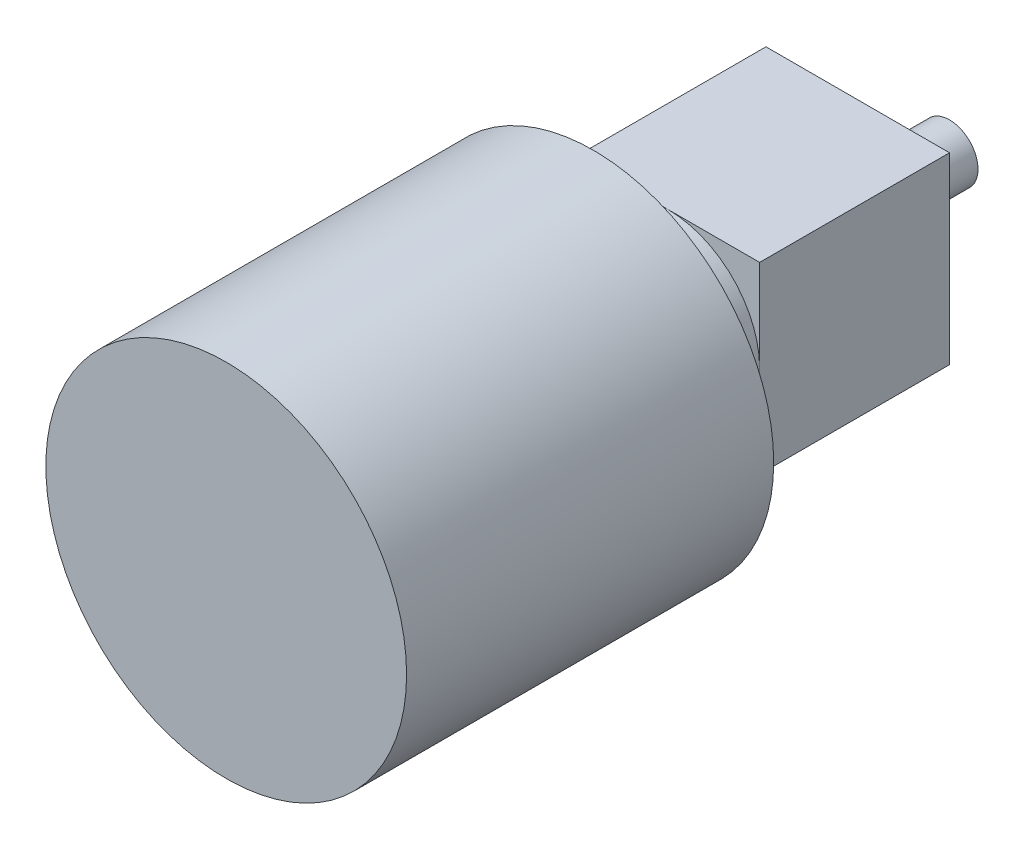
from build123d import *

# Parameters (mm, degrees)
SKETCH1_W           = 29
SKETCH1_H           = 30
BOSS_EXTRUDE1_DEPTH = 29
SKETCH2_R           = 14.5
BOSS_EXTRUDE2_DEPTH = 11.78
SKETCH3_R           = 1.2
CUT_EXTRUDE1_DEPTH  = 2.5
SKETCH4_R           = 4.5
BOSS_EXTRUDE3_DEPTH = 6
SKETCH5_R           = 28.5
BOSS_EXTRUDE4_DEPTH = 58


with BuildPart() as part:
    # Sketch1 → Boss-Extrude1 (new body)
    with BuildSketch(Plane(origin=(0, 0, 0), x_dir=(1, 0, 0), z_dir=(0, 1, 0))):
        Rectangle(SKETCH1_W, SKETCH1_H)
    extrude(amount=BOSS_EXTRUDE1_DEPTH)

    # Sketch2 → Boss-Extrude2 (add)
    with BuildSketch(Plane.XY.offset(15)):
        with Locations((0, 14.5)):
            Circle(SKETCH2_R)
    extrude(amount=BOSS_EXTRUDE2_DEPTH)

    # Sketch3 → Cut-Extrude1 (cut)
    with BuildSketch(Plane.XZ):
        with Locations((-10, 12)):
            Circle(SKETCH3_R)
        with Locations((10, 12)):
            Circle(SKETCH3_R)
        with Locations((0, -11.5)):
            Circle(SKETCH3_R)
    extrude(amount=-CUT_EXTRUDE1_DEPTH, mode=Mode.SUBTRACT)

    # Sketch4 → Boss-Extrude3 (add)
    with BuildSketch(Plane(origin=(0, 0, -15), x_dir=(-1, 0, 0), z_dir=(0, 0, -1))):
        with Locations((-8.5, 23)):
            Circle(SKETCH4_R)
    extrude(amount=BOSS_EXTRUDE3_DEPTH)

    # Sketch5 → Boss-Extrude4 (add)
    with BuildSketch(Plane.XY.offset(26.78)):
        with Locations((0, 14.5)):
            Circle(SKETCH5_R)
    extrude(amount=BOSS_EXTRUDE4_DEPTH)


solid = part.part
